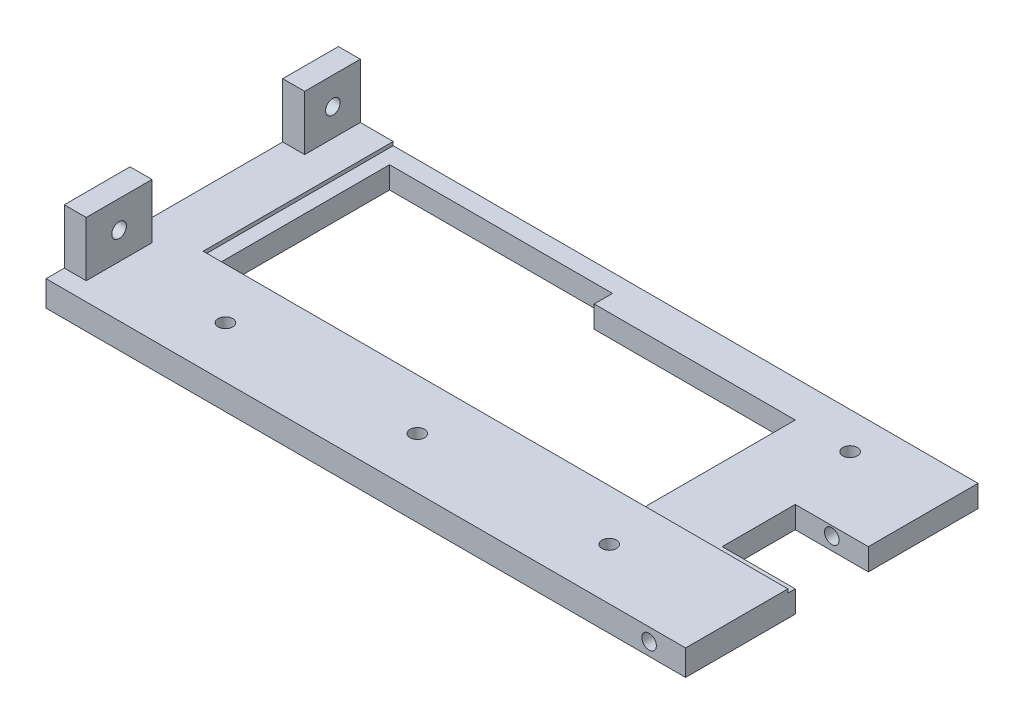
from build123d import *

# Parameters (mm, degrees)
SKETCH1_W               = 175
SKETCH1_H               = 80
BOSS_EXTRUDE1_DEPTH     = 7
SKETCH2_R               = 2
CUT_EXTRUDE1_DEPTH      = 10
SKETCH3_W               = 160
SKETCH3_H               = 52
CUT_EXTRUDE2_DEPTH      = 1
CUT_EXTRUDE3_DEPTH      = 10
SKETCH7_W               = 6
SKETCH7_H               = 15.226692755
SKETCH7_H_2             = 18
BOSS_EXTRUDE3_DEPTH     = 15
SKETCH8_R               = 2
CUT_EXTRUDE4_DEPTH      = 15
SKETCH9_W               = 20
SKETCH9_H               = 20
CUT_EXTRUDE5_DEPTH      = 15
SKETCH10_R              = 2
CUT_EXTRUDE7_DEPTH      = 51
CUT_EXTRUDE7_DEPTH_BACK = 31
SKETCH11_R              = 2
CUT_EXTRUDE8_DEPTH      = 10


with BuildPart() as part:
    # Sketch1 → Boss-Extrude1 (new body)
    with BuildSketch(Plane(origin=(0, 0, 0), x_dir=(1, 0, 0), z_dir=(0, 1, 0))):
        with Locations((-2.383449883, -6.993006993)):
            Rectangle(SKETCH1_W, SKETCH1_H)
    extrude(amount=BOSS_EXTRUDE1_DEPTH)

    # Sketch2 → Cut-Extrude1 (cut)
    with BuildSketch(Plane(origin=(0, 7, 0), x_dir=(1, 0, 0), z_dir=(0, 1, 0))):
        with Locations((-54.883449883, -32.893006993)):
            Circle(SKETCH2_R)
        with Locations((-2.383449883, -32.893006993)):
            Circle(SKETCH2_R)
        with Locations((50.116550117, -32.893006993)):
            Circle(SKETCH2_R)
    extrude(amount=-CUT_EXTRUDE1_DEPTH, mode=Mode.SUBTRACT)

    # Sketch3 → Cut-Extrude2 (cut)
    with BuildSketch(Plane(origin=(0, 7, 0), x_dir=(1, 0, 0), z_dir=(0, 1, 0))):
        with Locations((5.116550117, 7.006993007)):
            Rectangle(SKETCH3_W, SKETCH3_H)
    extrude(amount=-CUT_EXTRUDE2_DEPTH, mode=Mode.SUBTRACT)

    # Sketch6 → Cut-Extrude3 (cut)
    with BuildSketch(Plane(origin=(0, 6, 0), x_dir=(1, 0, 0), z_dir=(0, 1, 0))):
        Polygon((-70.883449883, 23.006993007), (-70.883449883, -18.993006993), (45.116550117, -18.993006993), (45.116550117, 23.006993007), (-9.883449883, 23.006993007), (-9.883449883, 28.006993007), (-70.883449883, 28.006993007), align=None)
    extrude(amount=-CUT_EXTRUDE3_DEPTH, mode=Mode.SUBTRACT)

    # Sketch7 → Boss-Extrude3 (add)
    with BuildSketch(Plane(origin=(0, 7, 0), x_dir=(1, 0, 0), z_dir=(0, 1, 0))):
        with Locations((-86.883449883, 25.39364663)):
            Rectangle(SKETCH7_W, SKETCH7_H)
        with Locations((-86.883449883, -32.993006993)):
            Rectangle(SKETCH7_W, SKETCH7_H_2)
    extrude(amount=BOSS_EXTRUDE3_DEPTH)

    # Sketch8 → Cut-Extrude4 (cut)
    with BuildSketch(Plane(origin=(-83.883449883, 0, 0), x_dir=(0, 0, -1), z_dir=(1, 0, 0))):
        with Locations((25.506993007, 14.5)):
            Circle(SKETCH8_R)
        with Locations((-32.993006993, 14.5)):
            Circle(SKETCH8_R)
    extrude(amount=-CUT_EXTRUDE4_DEPTH, mode=Mode.SUBTRACT)

    # Sketch9 → Cut-Extrude5 (cut)
    with BuildSketch(Plane.XZ):
        with Locations((75.116550117, 6.993006993)):
            Rectangle(SKETCH9_W, SKETCH9_H)
    extrude(amount=-CUT_EXTRUDE5_DEPTH, mode=Mode.SUBTRACT)

    # Sketch10 → Cut-Extrude7 (cut, two sides)
    with BuildSketch(Plane.XY.offset(-3.006993007)) as cut_extrude7_sk:
        with Locations((75.116550117, 3.5)):
            Circle(SKETCH10_R)
    extrude(amount=CUT_EXTRUDE7_DEPTH, mode=Mode.SUBTRACT)
    extrude(cut_extrude7_sk.sketch, amount=-CUT_EXTRUDE7_DEPTH_BACK, mode=Mode.SUBTRACT)

    # Sketch11 → Cut-Extrude8 (cut)
    with BuildSketch(Plane.XZ):
        with Locations((60.116550117, -23.006993007)):
            Circle(SKETCH11_R)
    extrude(amount=-CUT_EXTRUDE8_DEPTH, mode=Mode.SUBTRACT)


solid = part.part
